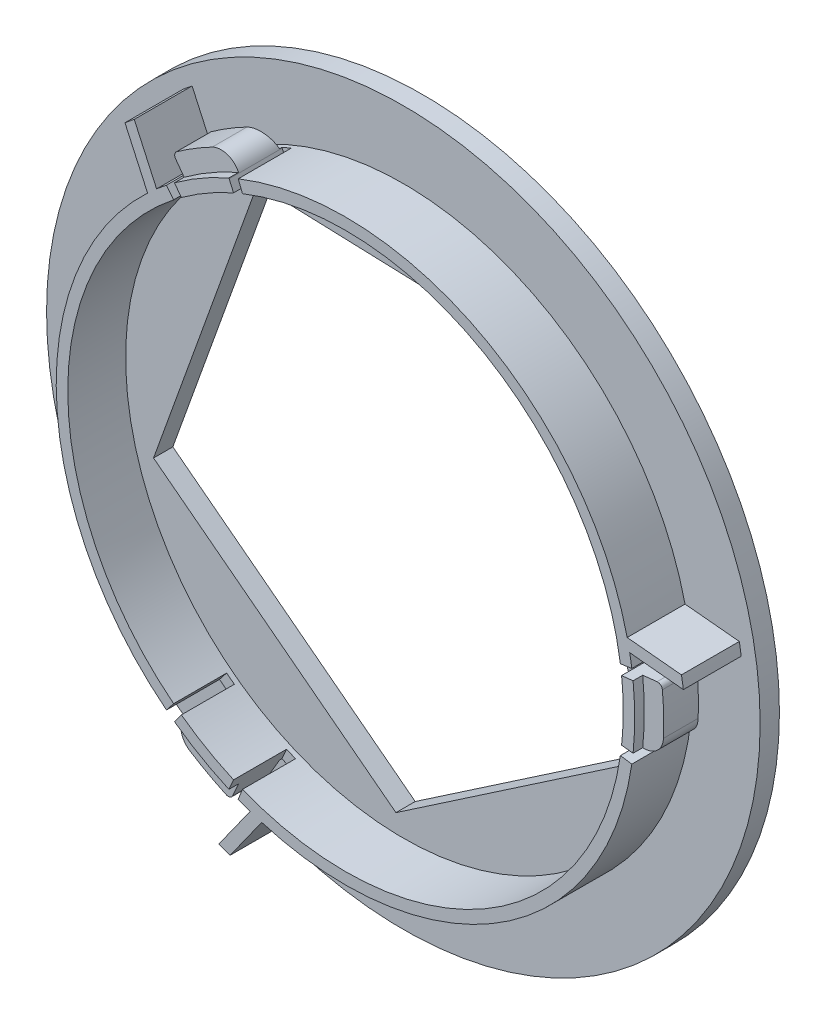
from build123d import *

# Parameters (mm, degrees)
SKETCH55_R               = 37
BOSS_EXTRUDE17_DEPTH     = 8
SKETCH56_R               = 37
SKETCH56_R_2             = 30
SKETCH56_R_3             = 28.8
CUT_EXTRUDE20_DEPTH      = 6
CUT_EXTRUDE21_DEPTH      = 5.5
FILLET1_R                = 0.5
FILLET2_R                = 2
BOSS_EXTRUDE18_START     = 6
BOSS_EXTRUDE18_DEPTH     = 6
CIRPATTERN1_COUNT        = 3
FILLET1_OF_CIRPATTERN1_R = 0.5
FILLET2_OF_CIRPATTERN1_R = 2


with BuildPart() as part:
    # Sketch55 → Boss-Extrude17 (new body)
    with BuildSketch(Plane.XY):
        Circle(SKETCH55_R)
        Polygon((-15.131119551888249, 22.33533974306702), (-25.90504070234881, -7.604599443277265), (-0.7697350404796751, -26.883764916532357), (25.354620105449243, -9.123888866834614), (16.52740298769779, 21.24243055544057), align=None, mode=Mode.SUBTRACT)
    extrude(amount=-BOSS_EXTRUDE17_DEPTH)

    # Sketch56 → Cut-Extrude20 (cut)
    # profile 1 of 2: a face of its own
    with BuildSketch(Plane.XY):
        Circle(SKETCH56_R)
        Circle(SKETCH56_R_2, mode=Mode.SUBTRACT)
    # profile 2 of 2: a face of its own
    with BuildSketch(Plane.XY):
        Circle(SKETCH56_R_3)
    extrude(amount=-CUT_EXTRUDE20_DEPTH, mode=Mode.SUBTRACT)

    # Sweep1: sweep along a path in Sketch58
    with BuildLine(Plane.XY.offset(-1)) as sweep1_path:
        ThreePointArc((32.05951496825865, -3.5), (32.25, 0), (32.05951496825865, 3.5))
    # Sketch59 → Sweep1 (sweep)
    with BuildSketch(Plane(origin=(0, 0, 0), x_dir=(1, 0, 0), z_dir=(0, 1, 0))):
        Polygon((32, 1.0000000000000009), (32, 4.6), (30, 5.25), (30, 1.0000000000000009), align=None)
    sweep1 = sweep(path=sweep1_path.line)

    # Sketch60 → Cut-Extrude21 (cut)
    with BuildSketch(Plane.XY):
        with BuildLine():
            Line((29.691011106511933, 4.294631471149185), (28.503370662251456, 4.122846212303217))
            ThreePointArc((28.503370662251456, 4.122846212303217), (28.570983048615947, 3.624765873225473), (28.629892436770504, 3.125581395348848))
            Line((28.629892436770504, 3.125581395348848), (29.822804621635946, 3.255813953488383))
            ThreePointArc((29.822804621635946, 3.255813953488383), (29.761440675641612, 3.7757977846098676), (29.691011106511933, 4.294631471149185))
        make_face()
        with BuildLine():
            Line((29.822804621635946, -3.255813953488384), (28.629892436770504, -3.1255813953488487))
            ThreePointArc((28.629892436770504, -3.1255813953488487), (28.57098304861595, -3.6247658732254733), (28.503370662251456, -4.122846212303217))
            Line((28.503370662251456, -4.122846212303217), (29.691011106511933, -4.294631471149185))
            ThreePointArc((29.691011106511933, -4.294631471149185), (29.761440675641612, -3.7757977846098676), (29.822804621635946, -3.255813953488384))
        make_face()
    cut_extrude21 = extrude(amount=-CUT_EXTRUDE21_DEPTH, mode=Mode.SUBTRACT)

    # Fillet1
    fillet1_edges = [part.edges().sort_by_distance(p)[0] for p in [
        (31.810991596411686, 3.472868217054266, -2.8000000000000003),
    ]]
    fillet(fillet1_edges, radius=FILLET1_R)

    # Fillet2
    fillet2_edges = [part.edges().sort_by_distance(p)[0] for p in [
        (31.810991596411686, -3.4728682170542657, -2.8000000000000003),
    ]]
    fillet(fillet2_edges, radius=FILLET2_R)

    # Sketch62 → Boss-Extrude18 (add)
    with BuildSketch(Plane.XY.offset(-6).offset(BOSS_EXTRUDE18_START)):
        with BuildLine():
            Line((35.035393105684086, 5.067665135956038), (28.225251300389694, 5.724961923877751))
            ThreePointArc((28.225251300389694, 5.724961923877751), (28.092883468127496, 6.342704348005581), (27.946997326196957, 6.957394659607891))
            Line((27.946997326196957, 6.957394659607891), (34.836258824834346, 6.29246144915893))
            ThreePointArc((34.836258824834346, 6.29246144915893), (34.94119298731927, 5.680935893223171), (35.035393105684086, 5.067665135956038))
        make_face()
    boss_extrude18 = extrude(amount=-BOSS_EXTRUDE18_DEPTH)

    # CirPattern1: Sweep1, Cut-Extrude21, Boss-Extrude18 ×3 about axis
    cirpattern1_axis = Axis((-3.9e-16, -9.2e-16, 0), (0, 0, 1))
    add([sweep1.rotate(cirpattern1_axis, i * 360 / CIRPATTERN1_COUNT) for i in range(1, CIRPATTERN1_COUNT)])
    add([cut_extrude21.rotate(cirpattern1_axis, i * 360 / CIRPATTERN1_COUNT) for i in range(1, CIRPATTERN1_COUNT)], mode=Mode.SUBTRACT)
    add([boss_extrude18.rotate(cirpattern1_axis, i * 360 / CIRPATTERN1_COUNT) for i in range(1, CIRPATTERN1_COUNT)])

    # Fillet1 of CirPattern1
    fillet1_of_cirpattern1_edges = [part.edges().sort_by_distance(p)[0] for p in [
        (-18.9130878981704, 25.812692733538686, -2.8000000000000003),
        (-12.897903698241294, -29.28556095059294, -2.8000000000000003),
    ]]
    fillet(fillet1_of_cirpattern1_edges, radius=FILLET1_OF_CIRPATTERN1_R)

    # Fillet2 of CirPattern1
    fillet2_of_cirpattern1_edges = [part.edges().sort_by_distance(p)[0] for p in [
        (-12.897903698241274, 29.28556095059295, -2.8000000000000003),
        (-18.91308789817042, -25.81269273353867, -2.8000000000000003),
    ]]
    fillet(fillet2_of_cirpattern1_edges, radius=FILLET2_OF_CIRPATTERN1_R)


solid = part.part
